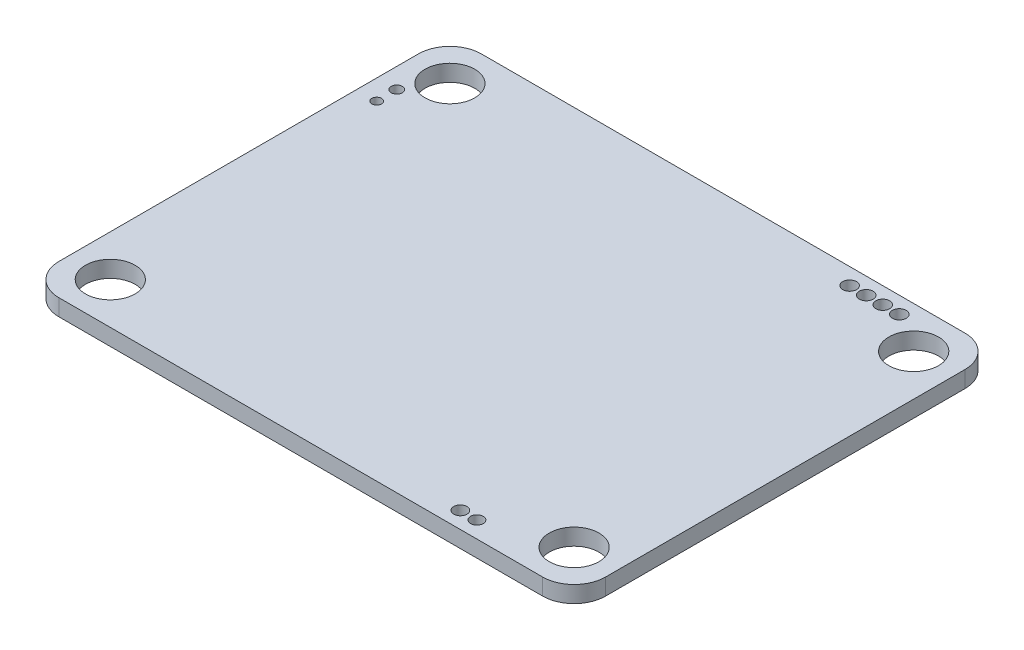
from build123d import *

# Parameters (mm, degrees)
SKETCH1_W           = 66
SKETCH1_H           = 51
SKETCH1_R           = 3
SKETCH1_R_2         = 0.837405072
SKETCH1_R_3         = 0.764054199
SKETCH1_R_4         = 0.803226567
SKETCH1_R_5         = 0.673310758
SKETCH1_R_6         = 0.589146913
BOSS_EXTRUDE1_DEPTH = 2
FILLET1_R           = 3.8
SKETCH2_W           = 5.836445367
SKETCH2_H           = 28.608084639
BOSS_EXTRUDE2_DEPTH = 1
SKETCH3_W           = 4.344585264
SKETCH3_H           = 28.608084639
BOSS_EXTRUDE3_DEPTH = 1
SKETCH4_R           = 1.622882134
SKETCH4_W           = 1.146541205
SKETCH4_H           = 3.7676464
SKETCH4_W_2         = 10.495224563
SKETCH4_H_2         = 14.476262407
SKETCH4_W_3         = 2.954262821
SKETCH4_H_3         = 4.462113597
SKETCH4_W_4         = 4.942556884
SKETCH4_H_4         = 3.116266577
SKETCH4_W_5         = 1.293345918
SKETCH4_H_5         = 3.748296022
BOSS_EXTRUDE4_DEPTH = 1


with BuildPart() as part:
    # Sketch1 → Boss-Extrude1 (new body)
    with BuildSketch(Plane.XZ.offset(-5.259536096)):
        with Locations((37.716985738, 148.797755553)):
            Rectangle(SKETCH1_W, SKETCH1_H)
        with Locations(Location((65.716985738, 128.297755553, 0), (0, 0, 270))):  # turned: the seam where the file's is
            Circle(SKETCH1_R, mode=Mode.SUBTRACT)
        with Locations(Location((9.716985738, 128.297755553, 0), (0, 0, 90))):  # turned: the seam where the file's is
            Circle(SKETCH1_R, mode=Mode.SUBTRACT)
        with Locations(Location((65.716985738, 169.297755553, 0), (0, 0, 90))):  # turned: the seam where the file's is
            Circle(SKETCH1_R, mode=Mode.SUBTRACT)
        with Locations(Location((9.716985738, 169.297755553, 0), (0, 0, 270))):  # turned: the seam where the file's is
            Circle(SKETCH1_R, mode=Mode.SUBTRACT)
        with Locations(Location((60.981346955, 125.297755553, 0), (0, 0, 270))):  # turned: the seam where the file's is
            Circle(SKETCH1_R_2, mode=Mode.SUBTRACT)
        with Locations(Location((58.981346955, 125.297755553, 0), (0, 0, 270))):  # turned: the seam where the file's is
            Circle(SKETCH1_R_2, mode=Mode.SUBTRACT)
        with Locations(Location((56.981346955, 125.297755553, 0), (0, 0, 270))):  # turned: the seam where the file's is
            Circle(SKETCH1_R_2, mode=Mode.SUBTRACT)
        with Locations(Location((54.981346955, 125.297755553, 0), (0, 0, 270))):  # turned: the seam where the file's is
            Circle(SKETCH1_R_2, mode=Mode.SUBTRACT)
        with Locations(Location((56.981346955, 172.297755553, 0), (0, 0, 270))):  # turned: the seam where the file's is
            Circle(SKETCH1_R_3, mode=Mode.SUBTRACT)
        with Locations(Location((54.981346955, 172.297755553, 0), (0, 0, 270))):  # turned: the seam where the file's is
            Circle(SKETCH1_R_4, mode=Mode.SUBTRACT)
        with Locations(Location((7.14174105, 132.13483961, 0), (0, 0, 270))):  # turned: the seam where the file's is
            Circle(SKETCH1_R_5, mode=Mode.SUBTRACT)
        with Locations(Location((7.14174105, 134.559866184, 0), (0, 0, 270))):  # turned: the seam where the file's is
            Circle(SKETCH1_R_6, mode=Mode.SUBTRACT)
    extrude(amount=BOSS_EXTRUDE1_DEPTH)

    # Fillet1
    fillet1_edges = [part.edges().sort_by_distance(p)[0] for p in [
        (70.716985738, 4.259536096, 123.297755553),
        (4.716985738, 4.259536096, 123.297755553),
        (4.716985738, 4.259536096, 174.297755553),
        (70.716985738, 4.259536096, 174.297755553),
    ]]
    fillet(fillet1_edges, radius=FILLET1_R)

    # Sketch2 → Boss-Extrude2 (add)
    with BuildSketch(Plane.XZ.offset(-3.259536096)):
        with Locations((9.268800109, 148.797755553)):
            Rectangle(SKETCH2_W, SKETCH2_H)
    extrude(amount=BOSS_EXTRUDE2_DEPTH)

    # Sketch3 → Boss-Extrude3 (add)
    with BuildSketch(Plane.XZ.offset(-2.259536096)):
        with Locations((10.01473016, 148.797755553)):
            Rectangle(SKETCH3_W, SKETCH3_H)
    extrude(amount=BOSS_EXTRUDE3_DEPTH)

    # Sketch4 → Boss-Extrude4 (add)
    with BuildSketch(Plane.XZ.offset(-3.259536096)):
        with Locations(Location((29.756180169, 164.261204908, 0), (0, 0, 90))):  # turned: the seam where the file's is
            Circle(SKETCH4_R)
        with Locations((52.18819816, 159.346174618)):
            Rectangle(SKETCH4_W, SKETCH4_H)
        with Locations((28.060742514, 141.548791384)):
            Rectangle(SKETCH4_W_2, SKETCH4_H_2)
        with Locations((20.678530081, 167.750382062)):
            Rectangle(SKETCH4_W_3, SKETCH4_H_3)
        with Locations((52.621525564, 169.30851535)):
            Rectangle(SKETCH4_W_4, SKETCH4_H_4)
        with Locations((54.18819816, 159.346174618)):
            Rectangle(SKETCH4_W, SKETCH4_H)
        with Locations((50.18819816, 159.346174618)):
            Rectangle(SKETCH4_W, SKETCH4_H)
        with Locations((48.18819816, 159.346174618)):
            Rectangle(SKETCH4_W, SKETCH4_H)
        with Locations((46.18819816, 159.346174618)):
            Rectangle(SKETCH4_W, SKETCH4_H)
        with Locations((44.18819816, 159.346174618)):
            Rectangle(SKETCH4_W, SKETCH4_H)
        with Locations((42.18819816, 159.346174618)):
            Rectangle(SKETCH4_W, SKETCH4_H)
        with Locations((40.18819816, 159.346174618)):
            Rectangle(SKETCH4_W, SKETCH4_H)
        with Locations((38.18819816, 159.346174618)):
            Rectangle(SKETCH4_W, SKETCH4_H)
        with Locations((36.18819816, 159.346174618)):
            Rectangle(SKETCH4_W, SKETCH4_H)
        with Locations((22.523111138, 126.647676881)):
            Rectangle(SKETCH4_W_5, SKETCH4_H_5)
        with Locations((17.523111138, 126.647676881)):
            Rectangle(SKETCH4_W_5, SKETCH4_H_5)
        with Locations((27.523111138, 126.647676881)):
            Rectangle(SKETCH4_W_5, SKETCH4_H_5)
        with Locations((32.523111138, 126.647676881)):
            Rectangle(SKETCH4_W_5, SKETCH4_H_5)
        with Locations((37.523111138, 126.647676881)):
            Rectangle(SKETCH4_W_5, SKETCH4_H_5)
    extrude(amount=BOSS_EXTRUDE4_DEPTH)


solid = part.part
